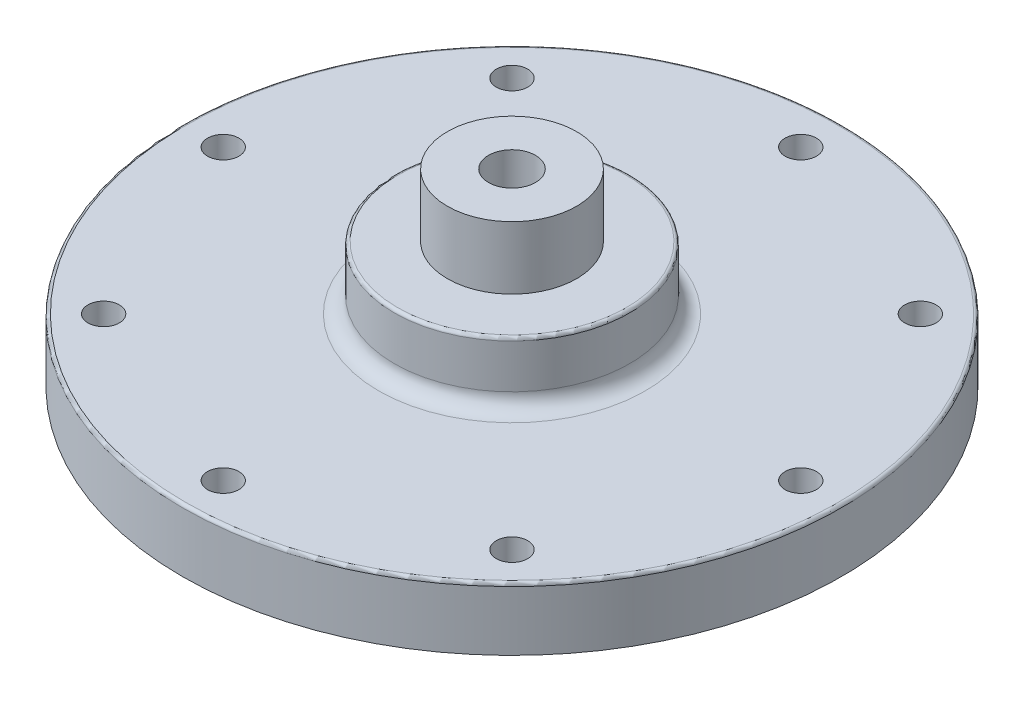
from build123d import *

# Parameters (mm, degrees)
SKETCH1_R                           = 66.675
FLANGE_DEPTH                        = 12.7
BOLT_HOLES_D                        = 6.35
BOLT_HOLES_DEPTH                    = 12.7
PIN_HOLES_D                         = 6.35
PIN_HOLES_DEPTH                     = 6.35
PIN_HOLES_TIP                       = 1.907732465
SKETCH2_R                           = 23.8125
SKETCH2_R_2                         = 12.7
FLOW_EXTRUDE_DEPTH                  = 12.7
SKETCH6_R                           = 13.081
SKETCH6_R_2                         = 4.7625
NITROUS_CONNECTION_FLANGE_DEPTH     = 12.7
SKETCH12_R                          = 23.8125
INITIAL_ENTRY_IMPINGING_PLATE_DEPTH = 5.715
SKETCH14_R                          = 23.749
SKETCH15_R                          = 23.8125
SKETCH16_R                          = 12.7
FINAL_FLOW_CUT_DEPTH                = 6.35
TAP_HOLES_FOR_IMPINGING_PLATE_D     = 3.7973
TAP_HOLES_FOR_IMPINGING_PLATE_DEPTH = 12.7
TAP_HOLES_FOR_IMPINGING_PLATE_TIP   = 1.140824014
FLOW_EXTRUDE_FILLET_R               = 3.175
FINAL_FILLET_FOR_HANDLING_R         = 0.635


with BuildPart() as part:
    # Sketch1 → Flange (new body)
    with BuildSketch(Plane(origin=(0, 0, 0), x_dir=(1, 0, 0), z_dir=(0, 1, 0))):
        Circle(SKETCH1_R)
    extrude(amount=FLANGE_DEPTH)

    # Bolt Holes
    with Locations(Plane(origin=(0, 12.7, 0), x_dir=(1, 0, 0), z_dir=(0, 1, 0))):
        with Locations((41.309178157, -41.309178157), (0, -58.42), (-41.309178157, -41.309178157), (-58.42, 0), (-41.309178157, 41.309178157), (0, 58.42), (41.309178157, 41.309178157), (58.42, 0)):
            Hole(BOLT_HOLES_D / 2, depth=BOLT_HOLES_DEPTH)

    # Pin Holes
    with Locations(Plane(origin=(0, 0, 0), x_dir=(-1, 0, 0), z_dir=(0, -1, 0))):
        with Locations((22.356366119, -53.973042289), (-22.356366119, 53.973042289)):
            Hole(PIN_HOLES_D / 2, depth=PIN_HOLES_DEPTH)
            with Locations((0, 0, -(PIN_HOLES_DEPTH + PIN_HOLES_TIP / 2))):  # 118° drill point
                Cone(0, PIN_HOLES_D / 2, PIN_HOLES_TIP, mode=Mode.SUBTRACT)

    # Sketch2 → Flow Extrude (add)
    with BuildSketch(Plane(origin=(0, 12.7, 0), x_dir=(1, 0, 0), z_dir=(0, 1, 0))):
        Circle(SKETCH2_R)
        Circle(SKETCH2_R_2, mode=Mode.SUBTRACT)
    extrude(amount=FLOW_EXTRUDE_DEPTH)

    # Sketch6 → Nitrous Connection Flange (add)
    with BuildSketch(Plane(origin=(0, 25.4, 0), x_dir=(1, 0, 0), z_dir=(0, 1, 0))):
        Circle(SKETCH6_R)
        Circle(SKETCH6_R_2, mode=Mode.SUBTRACT)
    extrude(amount=NITROUS_CONNECTION_FLANGE_DEPTH)

    # Sketch12 → Initial Entry - Impinging Plate (cut)
    with BuildSketch(Plane.XZ):
        Circle(SKETCH12_R)
    extrude(amount=-INITIAL_ENTRY_IMPINGING_PLATE_DEPTH, mode=Mode.SUBTRACT)

    # Sketch14 → Impinging Plate Press Fit Cut section 0
    with BuildSketch(Plane(origin=(0, 6.35, 0), x_dir=(-1, 0, 0), z_dir=(0, -1, 0))):
        Circle(SKETCH14_R)
    # Sketch15 → Impinging Plate Press Fit Cut section 1
    with BuildSketch(Plane.XZ.offset(-5.715)):
        Circle(SKETCH15_R)
    loft(mode=Mode.SUBTRACT)

    # Sketch16 → Final Flow Cut (cut)
    with BuildSketch(Plane.XZ.offset(-6.35)):
        Circle(SKETCH16_R)
    extrude(amount=-FINAL_FLOW_CUT_DEPTH, mode=Mode.SUBTRACT)

    # Tap Holes for Impinging Plate
    with Locations(Plane(origin=(0, 6.35, 0), x_dir=(-1, 0, 0), z_dir=(0, -1, 0))):
        with Locations((0, 17.4625), (17.4625, 0), (0, -17.4625), (-17.4625, 0)):
            Hole(TAP_HOLES_FOR_IMPINGING_PLATE_D / 2, depth=TAP_HOLES_FOR_IMPINGING_PLATE_DEPTH)
            with Locations((0, 0, -(TAP_HOLES_FOR_IMPINGING_PLATE_DEPTH + TAP_HOLES_FOR_IMPINGING_PLATE_TIP / 2))):  # 118° drill point
                Cone(0, TAP_HOLES_FOR_IMPINGING_PLATE_D / 2, TAP_HOLES_FOR_IMPINGING_PLATE_TIP, mode=Mode.SUBTRACT)

    # Flow Extrude Fillet
    flow_extrude_fillet_edges = [part.edges().sort_by_distance(p)[0] for p in [
        (-23.8125, 12.7, 0),
    ]]
    fillet(flow_extrude_fillet_edges, radius=FLOW_EXTRUDE_FILLET_R)

    # Final Fillet for Handling
    final_fillet_for_handling_edges = [part.edges().sort_by_distance(p)[0] for p in [
        (-66.675, 12.7, 0),
        (-23.8125, 25.4, 0),
    ]]
    fillet(final_fillet_for_handling_edges, radius=FINAL_FILLET_FOR_HANDLING_R)


solid = part.part
